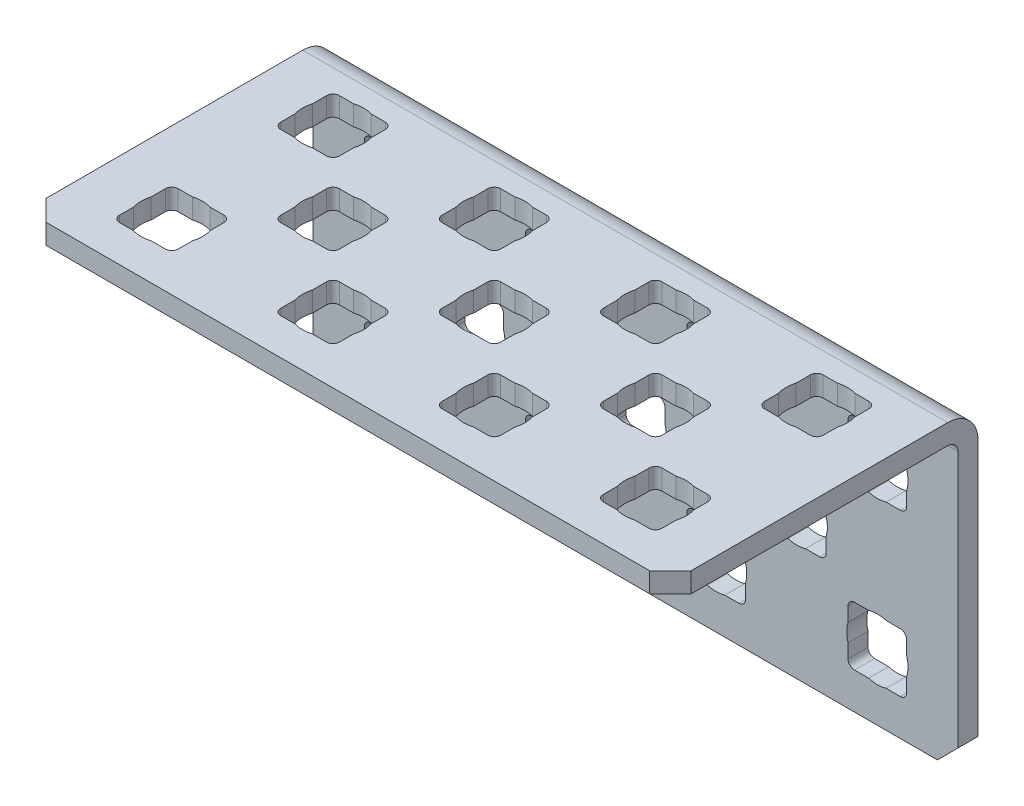
from build123d import *

# Parameters (mm, degrees)
SKETCH1_W            = 50.8
SKETCH1_H            = 24.2316
BOSS_EXTRUDE1_DEPTH  = 24.2316
SKETCH2_W            = 22.6568
SKETCH2_H            = 22.6568
CUT_EXTRUDE1_DEPTH   = 51.8
SKETCH3_W            = 4.6228
SKETCH3_H            = 4.6228
CUT_EXTRUDE2_DEPTH   = 25.2316
SKETCH4_W            = 4.6228
SKETCH4_H            = 4.6228
CUT_EXTRUDE3_DEPTH   = 25.2316
SKETCH5_W            = 4.6228
SKETCH5_H            = 4.6228
CUT_EXTRUDE4_DEPTH   = 25.2316
SKETCH6_W            = 4.6228
SKETCH6_H            = 4.6228
CUT_EXTRUDE5_DEPTH   = 25.2316
SKETCH7_W            = 4.6228
SKETCH7_H            = 4.6228
CUT_EXTRUDE6_DEPTH   = 25.2316
SKETCH8_W            = 4.6228
SKETCH8_H            = 4.6228
CUT_EXTRUDE7_DEPTH   = 25.2316
SKETCH9_W            = 4.6228
SKETCH9_H            = 4.6228
CUT_EXTRUDE8_DEPTH   = 25.2316
SKETCH10_W           = 4.6228
SKETCH10_H           = 4.6228
CUT_EXTRUDE9_DEPTH   = 25.2316
SKETCH11_W           = 4.6228
SKETCH11_H           = 4.6228
CUT_EXTRUDE10_DEPTH  = 25.2316
SKETCH12_W           = 4.6228
SKETCH12_H           = 4.6228
CUT_EXTRUDE11_DEPTH  = 25.2316
SKETCH13_W           = 4.6228
SKETCH13_H           = 4.6228
CUT_EXTRUDE12_DEPTH  = 2.5748
SKETCH14_W           = 4.6228
SKETCH14_H           = 4.6228
CUT_EXTRUDE13_DEPTH  = 2.5748
SKETCH15_W           = 4.6228
SKETCH15_H           = 4.6228
CUT_EXTRUDE14_DEPTH  = 2.5748
SKETCH16_W           = 4.6228
SKETCH16_H           = 4.6228
CUT_EXTRUDE15_DEPTH  = 2.5748
SKETCH17_W           = 4.6228
SKETCH17_H           = 4.6228
CUT_EXTRUDE16_DEPTH  = 2.5748
SKETCH18_W           = 4.6228
SKETCH18_H           = 4.6228
CUT_EXTRUDE17_DEPTH  = 2.5748
SKETCH19_W           = 4.6228
SKETCH19_H           = 4.6228
CUT_EXTRUDE18_DEPTH  = 2.5748
SKETCH20_W           = 4.6228
SKETCH20_H           = 4.6228
CUT_EXTRUDE19_DEPTH  = 2.5748
SKETCH21_W           = 4.6228
SKETCH21_H           = 4.6228
CUT_EXTRUDE20_DEPTH  = 2.5748
SKETCH22_W           = 4.6228
SKETCH22_H           = 4.6228
CUT_EXTRUDE21_DEPTH  = 2.5748
SKETCH23_W           = 4.6228
SKETCH23_H           = 4.6228
CUT_EXTRUDE22_DEPTH  = 2.5748
SKETCH24_W           = 4.6228
SKETCH24_H           = 4.6228
CUT_EXTRUDE23_DEPTH  = 2.5748
CHAMFER1_SIZE        = 1.6256
FILLET1_R            = 0.508
FILLET2_R            = 0.8128
FILLET3_R            = 2.3876
SKETCH25_R           = 2.413
CUT_EXTRUDE24_DEPTH  = 2.54
LPATTERN1_COUNT      = 4
LPATTERN1_PITCH      = 12.7
LPATTERN1_COUNT_DIR2 = 2
LPATTERN1_PITCH_DIR2 = 12.7
SKETCH26_R           = 2.413
CUT_EXTRUDE25_DEPTH  = 2.54
LPATTERN2_COUNT      = 3
LPATTERN2_PITCH      = 12.7
SKETCH27_R           = 2.413
CUT_EXTRUDE26_DEPTH  = 2.54
LPATTERN3_COUNT      = 4
LPATTERN3_PITCH      = 12.7
LPATTERN3_COUNT_DIR2 = 2
LPATTERN3_PITCH_DIR2 = 12.7
SKETCH28_R           = 2.413
CUT_EXTRUDE27_DEPTH  = 2.54
LPATTERN4_COUNT      = 3
LPATTERN4_PITCH      = 12.7


with BuildPart() as part:
    # Sketch1 → Boss-Extrude1 (new body)
    with BuildSketch(Plane.XZ.offset(12.1158)):
        with Locations((0, 12.1158)):
            Rectangle(SKETCH1_W, SKETCH1_H)
    extrude(amount=-BOSS_EXTRUDE1_DEPTH)

    # Sketch2 → Cut-Extrude1 (cut, through all)
    with BuildSketch(Plane.ZY.offset(25.4)):
        with Locations((12.9032, -0.7874)):
            Rectangle(SKETCH2_W, SKETCH2_H)
    extrude(amount=-CUT_EXTRUDE1_DEPTH, mode=Mode.SUBTRACT)

    # Sketch3 → Cut-Extrude2 (cut, through all)
    with BuildSketch(Plane(origin=(0, 12.1158, 0), x_dir=(-1, 0, 0), z_dir=(0, 1, 0))):
        with Locations((-19.05, 6.35)):
            Rectangle(SKETCH3_W, SKETCH3_H)
    extrude(amount=-CUT_EXTRUDE2_DEPTH, mode=Mode.SUBTRACT)

    # Sketch4 → Cut-Extrude3 (cut, through all)
    with BuildSketch(Plane(origin=(0, 12.1158, 0), x_dir=(-1, 0, 0), z_dir=(0, 1, 0))):
        with Locations((-6.35, 6.35)):
            Rectangle(SKETCH4_W, SKETCH4_H)
    extrude(amount=-CUT_EXTRUDE3_DEPTH, mode=Mode.SUBTRACT)

    # Sketch5 → Cut-Extrude4 (cut, through all)
    with BuildSketch(Plane(origin=(0, 12.1158, 0), x_dir=(-1, 0, 0), z_dir=(0, 1, 0))):
        with Locations((6.35, 6.35)):
            Rectangle(SKETCH5_W, SKETCH5_H)
    extrude(amount=-CUT_EXTRUDE4_DEPTH, mode=Mode.SUBTRACT)

    # Sketch6 → Cut-Extrude5 (cut, through all)
    with BuildSketch(Plane(origin=(0, 12.1158, 0), x_dir=(-1, 0, 0), z_dir=(0, 1, 0))):
        with Locations((19.05, 6.35)):
            Rectangle(SKETCH6_W, SKETCH6_H)
    extrude(amount=-CUT_EXTRUDE5_DEPTH, mode=Mode.SUBTRACT)

    # Sketch7 → Cut-Extrude6 (cut, through all)
    with BuildSketch(Plane(origin=(0, 12.1158, 0), x_dir=(-1, 0, 0), z_dir=(0, 1, 0))):
        with Locations((-12.7, 12.7)):
            Rectangle(SKETCH7_W, SKETCH7_H)
    extrude(amount=-CUT_EXTRUDE6_DEPTH, mode=Mode.SUBTRACT)

    # Sketch8 → Cut-Extrude7 (cut, through all)
    with BuildSketch(Plane(origin=(0, 12.1158, 0), x_dir=(-1, 0, 0), z_dir=(0, 1, 0))):
        with Locations((0, 12.7)):
            Rectangle(SKETCH8_W, SKETCH8_H)
    extrude(amount=-CUT_EXTRUDE7_DEPTH, mode=Mode.SUBTRACT)

    # Sketch9 → Cut-Extrude8 (cut, through all)
    with BuildSketch(Plane(origin=(0, 12.1158, 0), x_dir=(-1, 0, 0), z_dir=(0, 1, 0))):
        with Locations((12.7, 12.7)):
            Rectangle(SKETCH9_W, SKETCH9_H)
    extrude(amount=-CUT_EXTRUDE8_DEPTH, mode=Mode.SUBTRACT)

    # Sketch10 → Cut-Extrude9 (cut, through all)
    with BuildSketch(Plane(origin=(0, 12.1158, 0), x_dir=(-1, 0, 0), z_dir=(0, 1, 0))):
        with Locations((-19.05, 19.05)):
            Rectangle(SKETCH10_W, SKETCH10_H)
    extrude(amount=-CUT_EXTRUDE9_DEPTH, mode=Mode.SUBTRACT)

    # Sketch11 → Cut-Extrude10 (cut, through all)
    with BuildSketch(Plane(origin=(0, 12.1158, 0), x_dir=(-1, 0, 0), z_dir=(0, 1, 0))):
        with Locations((-6.35, 19.05)):
            Rectangle(SKETCH11_W, SKETCH11_H)
    extrude(amount=-CUT_EXTRUDE10_DEPTH, mode=Mode.SUBTRACT)

    # Sketch12 → Cut-Extrude11 (cut, through all)
    with BuildSketch(Plane(origin=(0, 12.1158, 0), x_dir=(-1, 0, 0), z_dir=(0, 1, 0))):
        with Locations((19.05, 19.05)):
            Rectangle(SKETCH12_W, SKETCH12_H)
    extrude(amount=-CUT_EXTRUDE11_DEPTH, mode=Mode.SUBTRACT)

    # Sketch13 → Cut-Extrude12 (cut, through all)
    with BuildSketch(Plane.XY.offset(1.5748)):
        with Locations((19.05, 5.7658)):
            Rectangle(SKETCH13_W, SKETCH13_H)
    extrude(amount=-CUT_EXTRUDE12_DEPTH, mode=Mode.SUBTRACT)

    # Sketch14 → Cut-Extrude13 (cut, through all)
    with BuildSketch(Plane.XY.offset(1.5748)):
        with Locations((6.35, 5.7658)):
            Rectangle(SKETCH14_W, SKETCH14_H)
    extrude(amount=-CUT_EXTRUDE13_DEPTH, mode=Mode.SUBTRACT)

    # Sketch15 → Cut-Extrude14 (cut, through all)
    with BuildSketch(Plane.XY.offset(1.5748)):
        with Locations((-6.35, 5.7658)):
            Rectangle(SKETCH15_W, SKETCH15_H)
    extrude(amount=-CUT_EXTRUDE14_DEPTH, mode=Mode.SUBTRACT)

    # Sketch16 → Cut-Extrude15 (cut, through all)
    with BuildSketch(Plane.XY.offset(1.5748)):
        with Locations((-19.05, 5.7658)):
            Rectangle(SKETCH16_W, SKETCH16_H)
    extrude(amount=-CUT_EXTRUDE15_DEPTH, mode=Mode.SUBTRACT)

    # Sketch17 → Cut-Extrude16 (cut, through all)
    with BuildSketch(Plane.XY.offset(1.5748)):
        with Locations((12.7, -0.5842)):
            Rectangle(SKETCH17_W, SKETCH17_H)
    extrude(amount=-CUT_EXTRUDE16_DEPTH, mode=Mode.SUBTRACT)

    # Sketch18 → Cut-Extrude17 (cut, through all)
    with BuildSketch(Plane.XY.offset(1.5748)):
        with Locations((0, -0.5842)):
            Rectangle(SKETCH18_W, SKETCH18_H)
    extrude(amount=-CUT_EXTRUDE17_DEPTH, mode=Mode.SUBTRACT)

    # Sketch19 → Cut-Extrude18 (cut, through all)
    with BuildSketch(Plane.XY.offset(1.5748)):
        with Locations((-12.7, -0.5842)):
            Rectangle(SKETCH19_W, SKETCH19_H)
    extrude(amount=-CUT_EXTRUDE18_DEPTH, mode=Mode.SUBTRACT)

    # Sketch20 → Cut-Extrude19 (cut, through all)
    with BuildSketch(Plane.XY.offset(1.5748)):
        with Locations((19.05, -6.9342)):
            Rectangle(SKETCH20_W, SKETCH20_H)
    extrude(amount=-CUT_EXTRUDE19_DEPTH, mode=Mode.SUBTRACT)

    # Sketch21 → Cut-Extrude20 (cut, through all)
    with BuildSketch(Plane.XY.offset(1.5748)):
        with Locations((6.35, -6.9342)):
            Rectangle(SKETCH21_W, SKETCH21_H)
    extrude(amount=-CUT_EXTRUDE20_DEPTH, mode=Mode.SUBTRACT)

    # Sketch22 → Cut-Extrude21 (cut, through all)
    with BuildSketch(Plane.XY.offset(1.5748)):
        with Locations((-19.05, -6.9342)):
            Rectangle(SKETCH22_W, SKETCH22_H)
    extrude(amount=-CUT_EXTRUDE21_DEPTH, mode=Mode.SUBTRACT)

    # Sketch23 → Cut-Extrude22 (cut, through all)
    with BuildSketch(Plane.XY.offset(1.5748)):
        with Locations((-6.35, -6.9342)):
            Rectangle(SKETCH23_W, SKETCH23_H)
    extrude(amount=-CUT_EXTRUDE22_DEPTH, mode=Mode.SUBTRACT)

    # Sketch24 → Cut-Extrude23 (cut, through all)
    with BuildSketch(Plane.XZ.offset(-10.541)):
        with Locations((-6.35, 19.05)):
            Rectangle(SKETCH24_W, SKETCH24_H)
    extrude(amount=-CUT_EXTRUDE23_DEPTH, mode=Mode.SUBTRACT)

    # Chamfer1
    chamfer1_edges = [part.edges().sort_by_distance(p)[0] for p in [
        (-25.4, -12.1158, 0.7874),
        (25.4, -12.1158, 0.7874),
        (-25.4, 11.3284, 24.2316),
        (25.4, 11.3284, 24.2316),
    ]]
    chamfer(chamfer1_edges, length=CHAMFER1_SIZE)

    # Fillet1
    fillet1_edges = [part.edges().sort_by_distance(p)[0] for p in [
        (10.3886, 11.3284, 15.0114),
        (10.3886, 11.3284, 10.3886),
        (15.0114, 11.3284, 10.3886),
        (15.0114, 11.3284, 15.0114),
        (-2.3114, 11.3284, 15.0114),
        (-2.3114, 11.3284, 10.3886),
        (2.3114, 11.3284, 10.3886),
        (2.3114, 11.3284, 15.0114),
        (-15.0114, 11.3284, 15.0114),
        (-15.0114, 11.3284, 10.3886),
        (-10.3886, 11.3284, 10.3886),
        (-10.3886, 11.3284, 15.0114),
        (16.7386, 11.3284, 21.3614),
        (16.7386, 11.3284, 16.7386),
        (21.3614, 11.3284, 16.7386),
        (21.3614, 11.3284, 21.3614),
        (4.0386, 11.3284, 21.3614),
        (4.0386, 11.3284, 16.7386),
        (8.6614, 11.3284, 16.7386),
        (8.6614, 11.3284, 21.3614),
        (-16.7386, 11.3284, 16.7386),
        (-16.7386, 11.3284, 21.3614),
        (-21.3614, 11.3284, 21.3614),
        (-21.3614, 11.3284, 16.7386),
        (21.3614, 3.4544, 0.7874),
        (16.7386, 3.4544, 0.7874),
        (16.7386, 8.0772, 0.7874),
        (21.3614, 8.0772, 0.7874),
        (8.6614, 3.4544, 0.7874),
        (4.0386, 3.4544, 0.7874),
        (4.0386, 8.0772, 0.7874),
        (8.6614, 8.0772, 0.7874),
        (-4.0386, 3.4544, 0.7874),
        (-8.6614, 3.4544, 0.7874),
        (-8.6614, 8.0772, 0.7874),
        (-4.0386, 8.0772, 0.7874),
        (-16.7386, 3.4544, 0.7874),
        (-21.3614, 3.4544, 0.7874),
        (-21.3614, 8.0772, 0.7874),
        (-16.7386, 8.0772, 0.7874),
        (15.0114, -2.8956, 0.7874),
        (10.3886, -2.8956, 0.7874),
        (10.3886, 1.7272, 0.7874),
        (15.0114, 1.7272, 0.7874),
        (2.3114, -2.8956, 0.7874),
        (-2.3114, -2.8956, 0.7874),
        (-2.3114, 1.7272, 0.7874),
        (2.3114, 1.7272, 0.7874),
        (16.7386, 11.3284, 8.6614),
        (16.7386, 11.3284, 4.0386),
        (21.3614, 11.3284, 4.0386),
        (21.3614, 11.3284, 8.6614),
        (-10.3886, -2.8956, 0.7874),
        (-15.0114, -2.8956, 0.7874),
        (-15.0114, 1.7272, 0.7874),
        (-10.3886, 1.7272, 0.7874),
        (21.3614, -9.2456, 0.7874),
        (16.7386, -9.2456, 0.7874),
        (16.7386, -4.6228, 0.7874),
        (21.3614, -4.6228, 0.7874),
        (8.6614, -9.2456, 0.7874),
        (4.0386, -9.2456, 0.7874),
        (4.0386, -4.6228, 0.7874),
        (8.6614, -4.6228, 0.7874),
        (-16.7386, -9.2456, 0.7874),
        (-21.3614, -9.2456, 0.7874),
        (-21.3614, -4.6228, 0.7874),
        (-16.7386, -4.6228, 0.7874),
        (-4.0386, -9.2456, 0.7874),
        (-8.6614, -9.2456, 0.7874),
        (-8.6614, -4.6228, 0.7874),
        (-4.0386, -4.6228, 0.7874),
        (-4.0386, 11.3284, 16.7386),
        (-8.6614, 11.3284, 16.7386),
        (-8.6614, 11.3284, 21.3614),
        (-4.0386, 11.3284, 21.3614),
        (4.0386, 11.3284, 8.6614),
        (4.0386, 11.3284, 4.0386),
        (8.6614, 11.3284, 4.0386),
        (8.6614, 11.3284, 8.6614),
        (-8.6614, 11.3284, 8.6614),
        (-8.6614, 11.3284, 4.0386),
        (-4.0386, 11.3284, 4.0386),
        (-4.0386, 11.3284, 8.6614),
        (-21.3614, 11.3284, 8.6614),
        (-21.3614, 11.3284, 4.0386),
        (-16.7386, 11.3284, 4.0386),
        (-16.7386, 11.3284, 8.6614),
    ]]
    fillet(fillet1_edges, radius=FILLET1_R)

    # Fillet2
    fillet2_edges = [part.edges().sort_by_distance(p)[0] for p in [
        (0, 10.541, 1.5748),
    ]]
    fillet(fillet2_edges, radius=FILLET2_R)

    # Fillet3
    fillet3_edges = [part.edges().sort_by_distance(p)[0] for p in [
        (0, 12.1158, 0),
    ]]
    fillet(fillet3_edges, radius=FILLET3_R)

    # Sketch25 → Cut-Extrude24 (cut)
    with BuildSketch(Plane(origin=(0, 0, 0), x_dir=(-1, 0, 0), z_dir=(0, 0, -1))):
        with Locations((-19.05, -6.9342)):
            Circle(SKETCH25_R)
    cut_extrude24 = extrude(amount=-CUT_EXTRUDE24_DEPTH, mode=Mode.SUBTRACT)

    # LPattern1: Cut-Extrude24 4 × 2
    with Locations(*[(-i * LPATTERN1_PITCH, j * LPATTERN1_PITCH_DIR2, 0) for i in range(LPATTERN1_COUNT) for j in range(LPATTERN1_COUNT_DIR2) if (i, j) != (0, 0)]):
        add(cut_extrude24, mode=Mode.SUBTRACT)

    # Sketch26 → Cut-Extrude25 (cut)
    with BuildSketch(Plane(origin=(0, 0, 0), x_dir=(-1, 0, 0), z_dir=(0, 0, -1))):
        with Locations((-12.7, -0.5842)):
            Circle(SKETCH26_R)
    cut_extrude25 = extrude(amount=-CUT_EXTRUDE25_DEPTH, mode=Mode.SUBTRACT)

    # LPattern2: Cut-Extrude25 ×3
    with Locations(*[(-i * LPATTERN2_PITCH, 0, 0) for i in range(1, LPATTERN2_COUNT)]):
        add(cut_extrude25, mode=Mode.SUBTRACT)

    # Sketch27 → Cut-Extrude26 (cut)
    with BuildSketch(Plane(origin=(0, 12.1158, 0), x_dir=(1, 0, 0), z_dir=(0, 1, 0))):
        with Locations((-19.05, -19.05)):
            Circle(SKETCH27_R)
    cut_extrude26 = extrude(amount=-CUT_EXTRUDE26_DEPTH, mode=Mode.SUBTRACT)

    # LPattern3: Cut-Extrude26 4 × 2
    with Locations(*[(i * LPATTERN3_PITCH, 0, -j * LPATTERN3_PITCH_DIR2) for i in range(LPATTERN3_COUNT) for j in range(LPATTERN3_COUNT_DIR2) if (i, j) != (0, 0)]):
        add(cut_extrude26, mode=Mode.SUBTRACT)

    # Sketch28 → Cut-Extrude27 (cut)
    with BuildSketch(Plane(origin=(0, 12.1158, 0), x_dir=(1, 0, 0), z_dir=(0, 1, 0))):
        with Locations((-12.7, -12.7)):
            Circle(SKETCH28_R)
    cut_extrude27 = extrude(amount=-CUT_EXTRUDE27_DEPTH, mode=Mode.SUBTRACT)

    # LPattern4: Cut-Extrude27 ×3
    with Locations(*[(i * LPATTERN4_PITCH, 0, 0) for i in range(1, LPATTERN4_COUNT)]):
        add(cut_extrude27, mode=Mode.SUBTRACT)


solid = part.part
